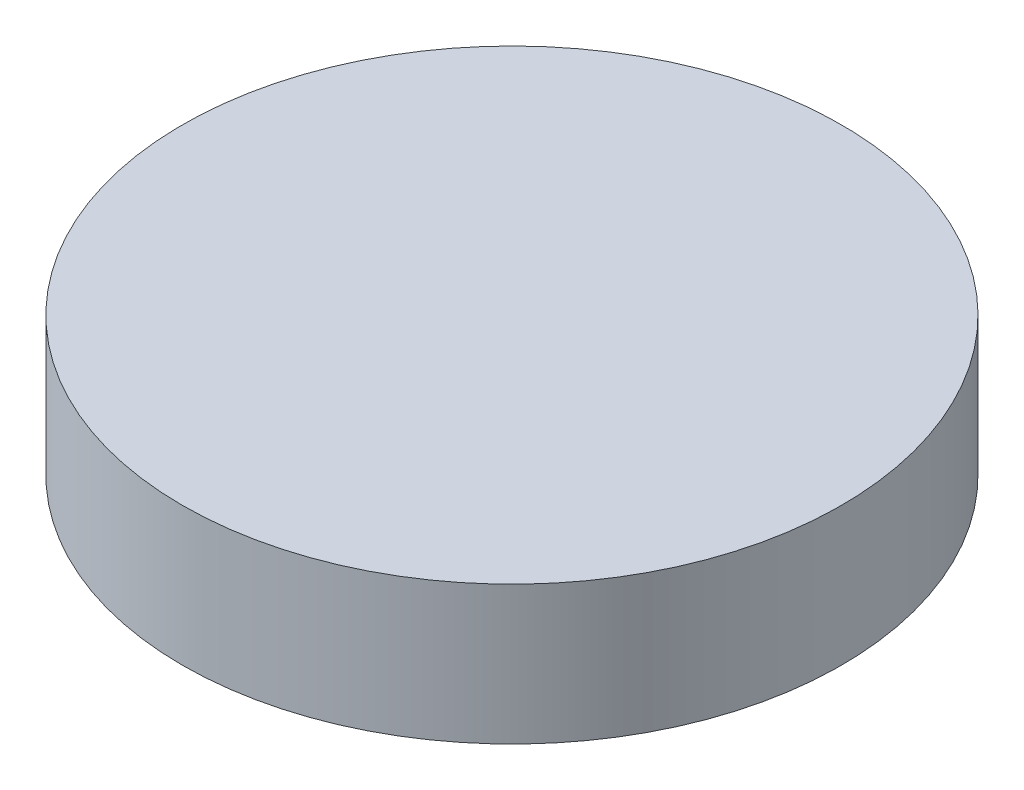
from build123d import *

# Parameters (mm, degrees)
SKETCH1_R           = 7.5565
BOSS_EXTRUDE1_DEPTH = 3.175


with BuildPart() as part:
    # Sketch1 → Boss-Extrude1 (new body)
    with BuildSketch(Plane(origin=(0, 0, 0), x_dir=(1, 0, 0), z_dir=(0, 1, 0))):
        Circle(SKETCH1_R)
    extrude(amount=BOSS_EXTRUDE1_DEPTH)


solid = part.part
